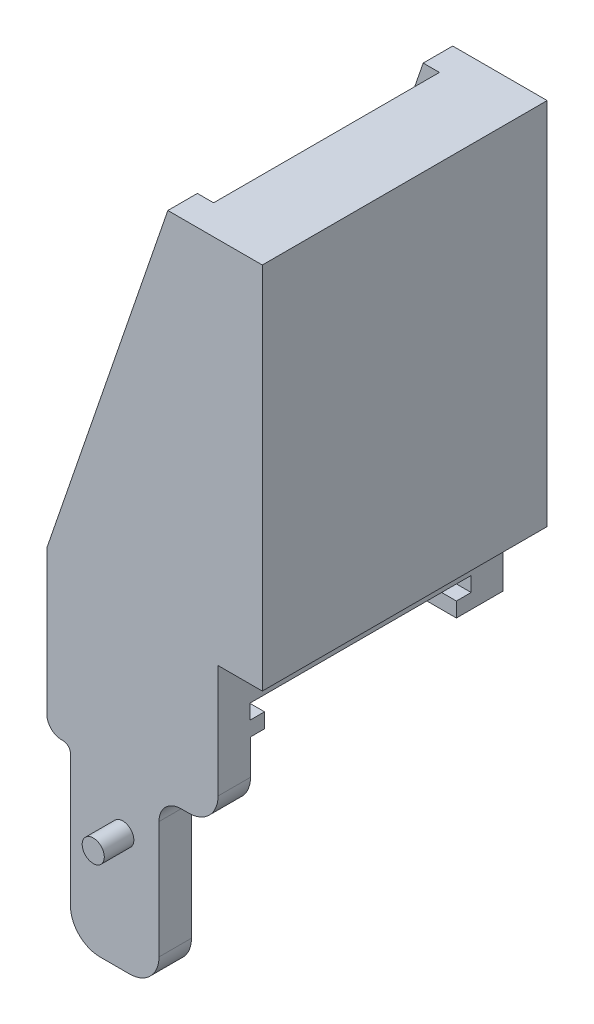
from build123d import *

# Parameters (mm, degrees)
SALIENTE_EXTRUIR1_DEPTH = 19.3
CROQUIS2_W              = 15.3
CROQUIS2_H              = 26.3
CORTAR_EXTRUIR1_DEPTH   = 9.3
CORTAR_EXTRUIR2_DEPTH   = 12.3
CROQUIS6_R              = 0.75
SALIENTE_EXTRUIR2_DEPTH = 2
CROQUIS7_W              = 19.3
CROQUIS7_H              = 25
SALIENTE_EXTRUIR3_DEPTH = 3


with BuildPart() as part:
    # Croquis1 → Saliente-Extruir1 (new body)
    with BuildSketch(Plane.XY):
        with BuildLine():
            Line((5.8, 23.05), (2.4, 23.05))
            Line((2.4, 23.05), (-5.8, -0.85))
            Line((-5.8, -0.85), (-5.8, -10.609737321))
            ThreePointArc((-5.8, -10.609737321), (-5.505459406, -11.318487649), (-4.795345946, -11.609726491))
            Line((-4.795345946, -11.609726491), (-4.702327027, -11.609293571))
            ThreePointArc((-4.702327027, -11.609293571), (-4.347270297, -11.754912992), (-4.2, -12.109288156))
            Line((-4.2, -12.109288156), (-4.2, -21.05))
            ThreePointArc((-4.2, -21.05), (-3.614213562, -22.464213562), (-2.2, -23.05))
            Line((-2.2, -23.05), (-0.2, -23.05))
            ThreePointArc((-0.2, -23.05), (1.214213562, -22.464213562), (1.8, -21.05))
            Line((1.8, -21.05), (1.8, -13.106955688))
            ThreePointArc((1.8, -13.106955688), (2.239339828, -12.046295517), (3.3, -11.606955688))
            Line((3.3, -11.606955688), (3.8, -11.606955688))
            ThreePointArc((3.8, -11.606955688), (5.214213562, -11.021169251), (5.8, -9.606955688))
            Line((5.8, -9.606955688), (5.8, 23.05))
        make_face()
    extrude(amount=SALIENTE_EXTRUIR1_DEPTH)

    # Croquis2 → Cortar-Extruir1 (cut)
    with BuildSketch(Plane.ZY.offset(5.8)):
        with Locations((9.65, 9.9)):
            Rectangle(CROQUIS2_W, CROQUIS2_H)
    extrude(amount=-CORTAR_EXTRUIR1_DEPTH, mode=Mode.SUBTRACT)

    # Croquis4 → Cortar-Extruir2 (cut)
    with BuildSketch(Plane.ZY.offset(5.8)):
        Polygon((2.15, -5.239890457), (2.15, -6.239890457), (3.15, -6.239890457), (3.15, -7.239890457), (-0.05, -7.239890457), (-0.05, -23.239890457), (17.1, -23.239890457), (17.1, -7.239890457), (16.15, -7.239890457), (16.15, -6.239890457), (17.15, -6.239890457), (17.15, -5.239890457), align=None)
    extrude(amount=-CORTAR_EXTRUIR2_DEPTH, mode=Mode.SUBTRACT)

    # Croquis6 → Saliente-Extruir2 (add)
    with BuildSketch(Plane.XY.offset(19.3)):
        with Locations((-0.655214383, -15.046201441)):
            Circle(CROQUIS6_R)
    extrude(amount=SALIENTE_EXTRUIR2_DEPTH)

    # Croquis7 → Saliente-Extruir3 (add)
    with BuildSketch(Plane(origin=(5.8, 0, 0), x_dir=(0, 0, -1), z_dir=(1, 0, 0))):
        with Locations((-9.65, 10.55)):
            Rectangle(CROQUIS7_W, CROQUIS7_H)
    extrude(amount=SALIENTE_EXTRUIR3_DEPTH)


solid = part.part
